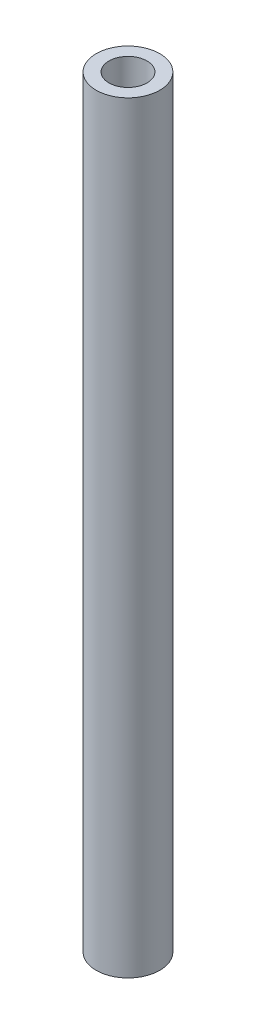
from build123d import *

# Parameters (mm, degrees)
SKETCH1_R           = 2.5
BOSS_EXTRUDE1_DEPTH = 60
SKETCH2_R           = 1.5
CUT_EXTRUDE1_DEPTH  = 61


with BuildPart() as part:
    # Sketch1 → Boss-Extrude1 (new body)
    with BuildSketch(Plane(origin=(0, 0, 0), x_dir=(1, 0, 0), z_dir=(0, 1, 0))):
        Circle(SKETCH1_R)
    extrude(amount=BOSS_EXTRUDE1_DEPTH)

    # Sketch2 → Cut-Extrude1 (cut, through all)
    with BuildSketch(Plane(origin=(0, 60, 0), x_dir=(1, 0, 0), z_dir=(0, 1, 0))):
        Circle(SKETCH2_R)
    extrude(amount=-CUT_EXTRUDE1_DEPTH, mode=Mode.SUBTRACT)


solid = part.part
